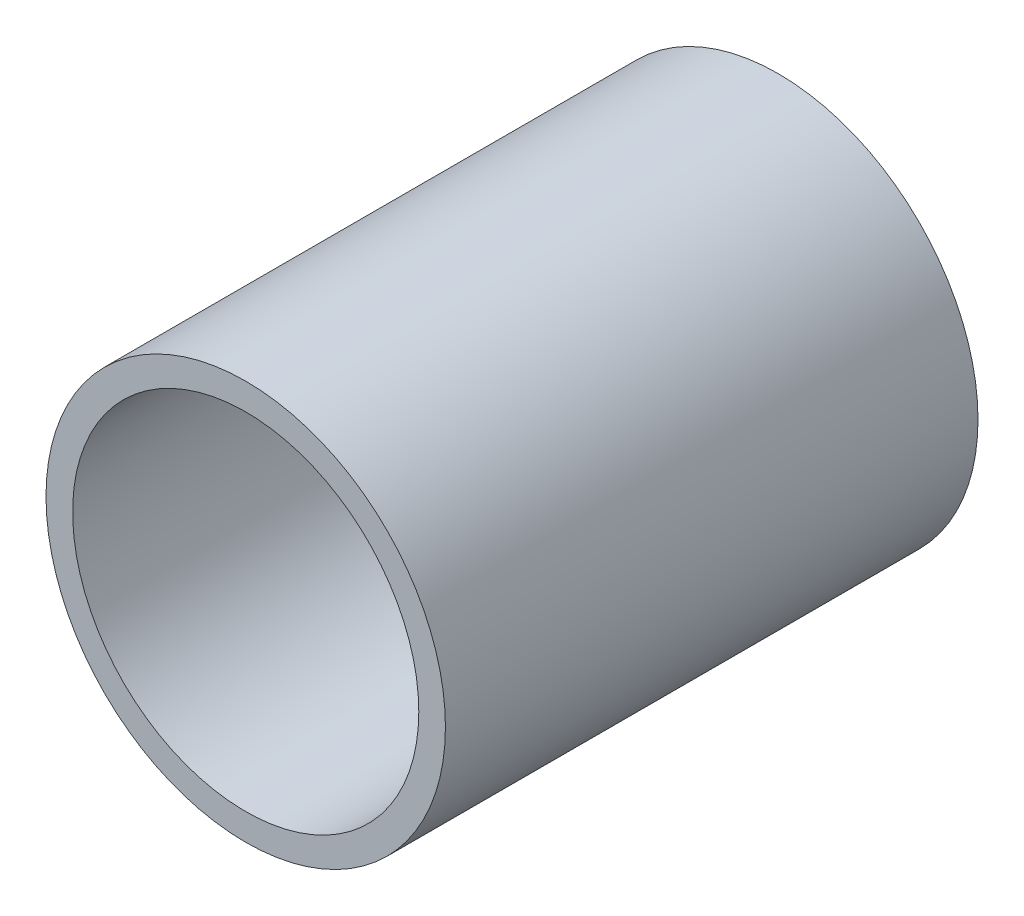
from build123d import *

# Parameters (mm, degrees)
SKETCH4_R           = 15
BOSS_EXTRUDE3_DEPTH = 40
SHELL1_T            = -2


with BuildPart() as part:
    # Sketch4 → Boss-Extrude3 (new body)
    with BuildSketch(Plane.XY):
        Circle(SKETCH4_R)
    extrude(amount=BOSS_EXTRUDE3_DEPTH)

    # Shell1
    shell1_openings = [part.faces().sort_by_distance(p)[0] for p in [
        (0, 0, 40),
    ]]
    offset(amount=SHELL1_T, openings=shell1_openings, kind=Kind.INTERSECTION)


solid = part.part
